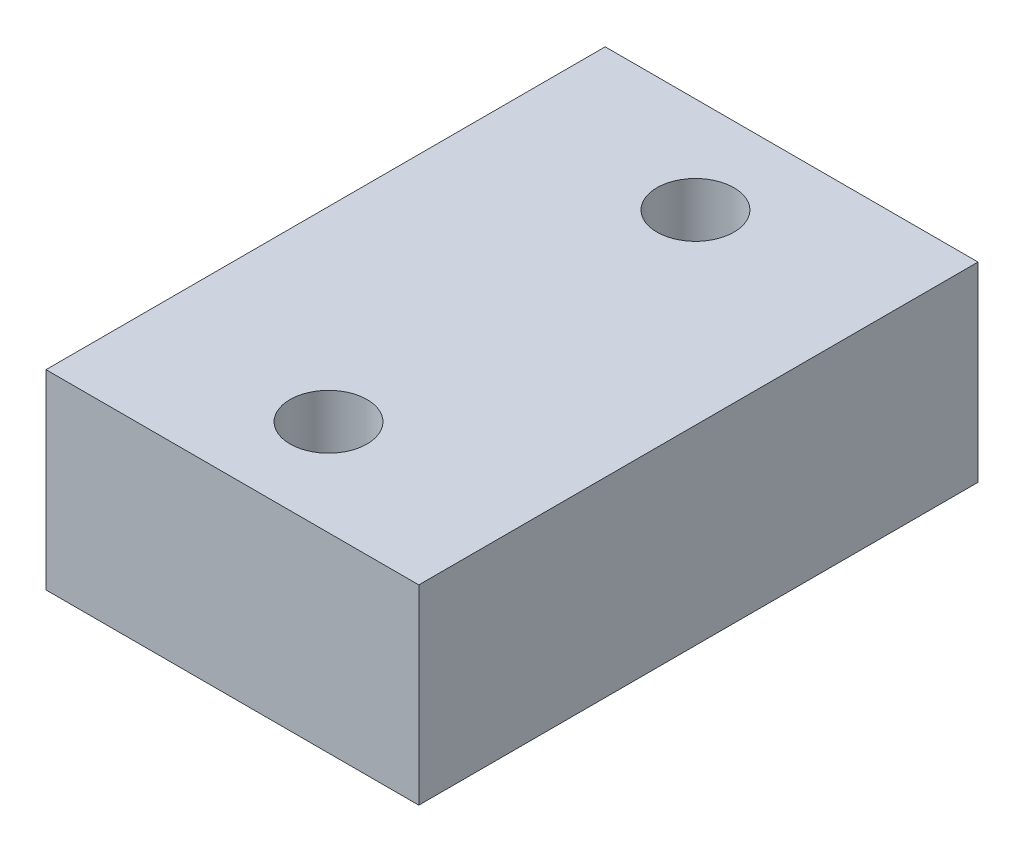
from build123d import *

# Parameters (mm, degrees)
SKETCH1_W           = 50.8
SKETCH1_H           = 76.2
BOSS_EXTRUDE1_DEPTH = 26
SKETCH2_R           = 5.25
CUT_EXTRUDE2_DEPTH  = 27


with BuildPart() as part:
    # Sketch1 → Boss-Extrude1 (new body)
    with BuildSketch(Plane(origin=(0, 0, 0), x_dir=(1, 0, 0), z_dir=(0, 1, 0))):
        Rectangle(SKETCH1_W, SKETCH1_H)
    extrude(amount=BOSS_EXTRUDE1_DEPTH)

    # Sketch2 → Cut-Extrude2 (cut, through all)
    with BuildSketch(Plane(origin=(0, 26, 0), x_dir=(1, 0, 0), z_dir=(0, 1, 0))):
        with Locations((0, 25)):
            Circle(SKETCH2_R)
        with Locations((0, -25)):
            Circle(SKETCH2_R)
    extrude(amount=-CUT_EXTRUDE2_DEPTH, mode=Mode.SUBTRACT)


solid = part.part
